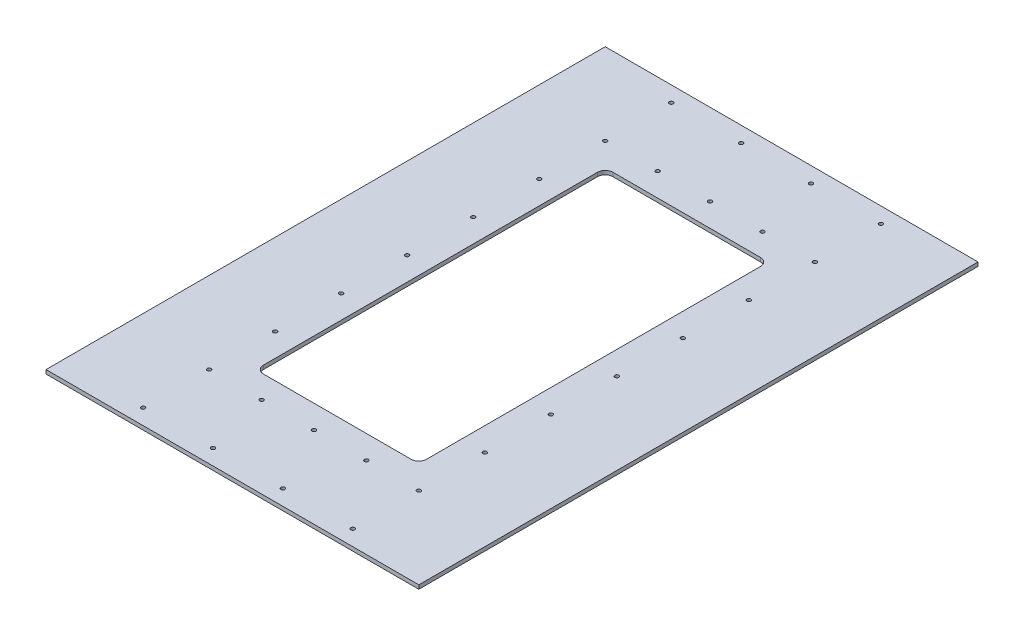
from build123d import *

# Parameters (mm, degrees)
SKETCH1_W                   = 609.6
SKETCH1_H                   = 914.4
BOSS_EXTRUDE1_DEPTH         = 6.35
SKETCH2_W                   = 266.7
SKETCH2_H                   = 571.5
CUT_EXTRUDE1_DEPTH          = 7.35
FILLET1_R                   = 12.7
SKETCH3_R                   = 3.175
CUT_EXTRUDE2_DEPTH          = 7.35
F_1_4_0_25_DIAMETER_HOLE1_D = 6.35
LPATTERN1_COUNT             = 4
LPATTERN1_PITCH             = 114.3
F_1_4_0_25_DIAMETER_HOLE2_D = 6.35
LPATTERN2_COUNT             = 4
LPATTERN2_PITCH             = 114.3


with BuildPart() as part:
    # Sketch1 → Boss-Extrude1 (new body)
    with BuildSketch(Plane(origin=(0, 609.6, 0), x_dir=(1, 0, 0), z_dir=(0, 1, 0))):
        Rectangle(SKETCH1_W, SKETCH1_H)
    extrude(amount=-BOSS_EXTRUDE1_DEPTH)

    # Sketch2 → Cut-Extrude1 (cut, through all)
    with BuildSketch(Plane(origin=(0, 609.6, 0), x_dir=(1, 0, 0), z_dir=(0, 1, 0))):
        Rectangle(SKETCH2_W, SKETCH2_H)
    extrude(amount=-CUT_EXTRUDE1_DEPTH, mode=Mode.SUBTRACT)

    # Fillet1
    fillet1_edges = [part.edges().sort_by_distance(p)[0] for p in [
        (-133.35, 606.425, 285.75),
        (-133.35, 606.425, -285.75),
        (133.35, 606.425, -285.75),
        (133.35, 606.425, 285.75),
    ]]
    fillet(fillet1_edges, radius=FILLET1_R)

    # Sketch3 → Cut-Extrude2 (cut, through all)
    with BuildSketch(Plane(origin=(0, 609.6, 0), x_dir=(1, 0, 0), z_dir=(0, 1, 0))):
        with Locations((-171.45, 215.9)):
            Circle(SKETCH3_R)
        with Locations((-171.45, 107.95)):
            Circle(SKETCH3_R)
        with Locations((-171.45, 0)):
            Circle(SKETCH3_R)
        with Locations((-171.45, -107.95)):
            Circle(SKETCH3_R)
        with Locations((-171.45, -215.9)):
            Circle(SKETCH3_R)
        with Locations((-171.45, -323.85)):
            Circle(SKETCH3_R)
        with Locations((-85.725, -323.85)):
            Circle(SKETCH3_R)
        with Locations((0, -323.85)):
            Circle(SKETCH3_R)
        with Locations((85.725, -323.85)):
            Circle(SKETCH3_R)
        with Locations((171.45, -323.85)):
            Circle(SKETCH3_R)
        with Locations((171.45, -215.9)):
            Circle(SKETCH3_R)
        with Locations((171.45, -107.95)):
            Circle(SKETCH3_R)
        with Locations((171.45, 0)):
            Circle(SKETCH3_R)
        with Locations((171.45, 107.95)):
            Circle(SKETCH3_R)
        with Locations((171.45, 215.9)):
            Circle(SKETCH3_R)
        with Locations((171.45, 323.85)):
            Circle(SKETCH3_R)
        with Locations((85.725, 323.85)):
            Circle(SKETCH3_R)
        with Locations((0, 323.85)):
            Circle(SKETCH3_R)
        with Locations((-85.725, 323.85)):
            Circle(SKETCH3_R)
        with Locations((-171.45, 323.85)):
            Circle(SKETCH3_R)
    extrude(amount=-CUT_EXTRUDE2_DEPTH, mode=Mode.SUBTRACT)

    # 1/4 (0.25) Diameter Hole1 (through all)
    with Locations(Plane(origin=(0, 609.6, 0), x_dir=(1, 0, 0), z_dir=(0, 1, 0))):
        with Locations((171.45, -431.8)):
            f_1_4_0_25_diameter_hole1 = Hole(F_1_4_0_25_DIAMETER_HOLE1_D / 2)

    # LPattern1: 1/4 (0.25) Diameter Hole1 ×4
    with Locations(*[(-i * LPATTERN1_PITCH, 0, 0) for i in range(1, LPATTERN1_COUNT)]):
        add(f_1_4_0_25_diameter_hole1, mode=Mode.SUBTRACT)

    # 1/4 (0.25) Diameter Hole2 (through all)
    with Locations(Plane(origin=(0, 609.6, 0), x_dir=(1, 0, 0), z_dir=(0, 1, 0))):
        with Locations((-171.45, 431.8)):
            f_1_4_0_25_diameter_hole2 = Hole(F_1_4_0_25_DIAMETER_HOLE2_D / 2)

    # LPattern2: 1/4 (0.25) Diameter Hole2 ×4
    with Locations(*[(i * LPATTERN2_PITCH, 0, 0) for i in range(1, LPATTERN2_COUNT)]):
        add(f_1_4_0_25_diameter_hole2, mode=Mode.SUBTRACT)


solid = part.part
